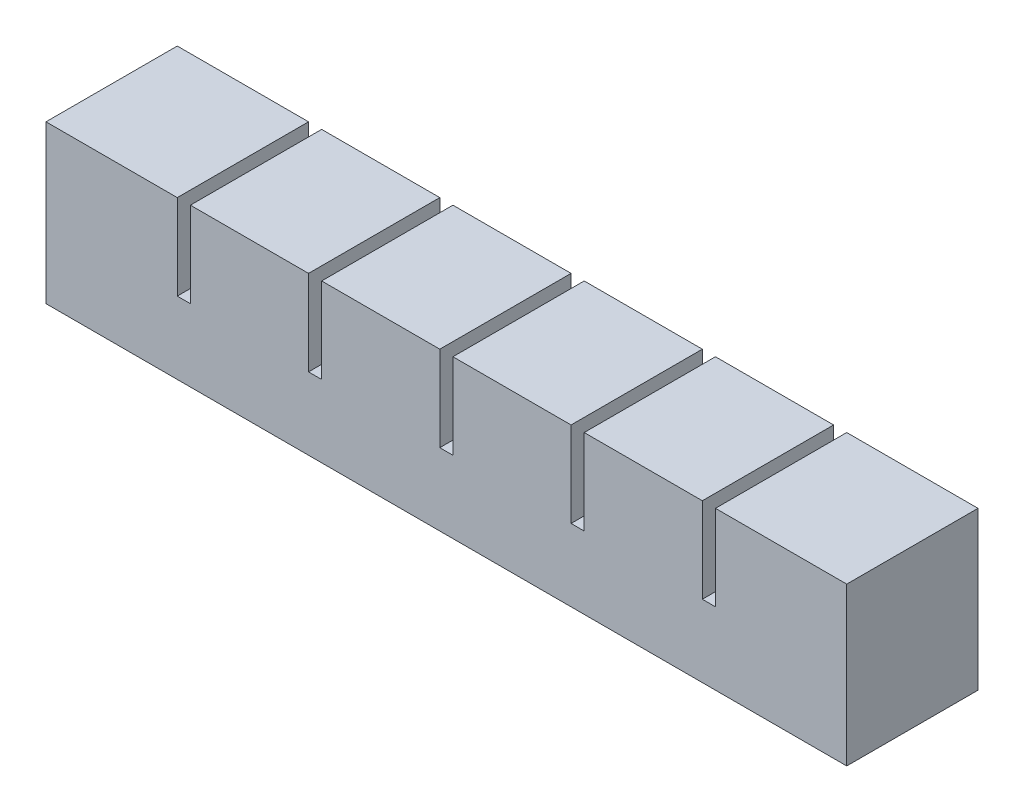
from build123d import *

# Parameters (mm, degrees)
SKETCH1_W           = 18
SKETCH1_H           = 18
BOSS_EXTRUDE1_DEPTH = 20
SKETCH2_W           = 8
SKETCH2_H           = 10
CUT_EXTRUDE1_DEPTH  = 13
SKETCH3_W           = 20
SKETCH3_H           = 5
BOSS_EXTRUDE2_DEPTH = 2
LPATTERN1_COUNT     = 6
LPATTERN1_PITCH     = 20
SKETCH4_W           = 20
SKETCH4_H           = 13
BOSS_EXTRUDE3_DEPTH = 2
SKETCH5_W           = 20
SKETCH5_H           = 18
BOSS_EXTRUDE4_DEPTH = 2
SKETCH6_W           = 108
SKETCH6_H           = 2
CUT_EXTRUDE2_DEPTH  = 2
SKETCH7_W           = 122
SKETCH7_H           = 20
BOSS_EXTRUDE5_DEPTH = 6


with BuildPart() as part:
    # Sketch1 → Boss-Extrude1 (new body)
    with BuildSketch(Plane.XY):
        with Locations((9, 9)):
            Rectangle(SKETCH1_W, SKETCH1_H)
    extrude(amount=BOSS_EXTRUDE1_DEPTH)

    # Sketch2 → Cut-Extrude1 (cut)
    with BuildSketch(Plane.XZ):
        with Locations((9, 10)):
            Rectangle(SKETCH2_W, SKETCH2_H)
    extrude(amount=-CUT_EXTRUDE1_DEPTH, mode=Mode.SUBTRACT)

    # Sketch3 → Boss-Extrude2 (add)
    with BuildSketch(Plane(origin=(18, 0, 0), x_dir=(0, 0, -1), z_dir=(1, 0, 0))):
        with Locations((-10, 2.5)):
            Rectangle(SKETCH3_W, SKETCH3_H)
    extrude(amount=BOSS_EXTRUDE2_DEPTH)


with BuildPart() as lpattern1_1:
    # LPattern1: pattern copy
    add(part.part.moved(Location(Vector(1, 0, 0) * (1 * LPATTERN1_PITCH))))


with BuildPart() as lpattern1_2:
    # LPattern1: pattern copy
    add(part.part.moved(Location(Vector(1, 0, 0) * (2 * LPATTERN1_PITCH))))


with BuildPart() as lpattern1_3:
    # LPattern1: pattern copy
    add(part.part.moved(Location(Vector(1, 0, 0) * (3 * LPATTERN1_PITCH))))


with BuildPart() as lpattern1_4:
    # LPattern1: pattern copy
    add(part.part.moved(Location(Vector(1, 0, 0) * (4 * LPATTERN1_PITCH))))


with BuildPart() as lpattern1_5:
    # LPattern1: pattern copy
    add(part.part.moved(Location(Vector(1, 0, 0) * (5 * LPATTERN1_PITCH))))


with BuildPart() as lpattern1_4_1:
    add(lpattern1_4.part)

    # Combine1: union LPattern1_5, part, LPattern1_1, LPattern1_2, LPattern1_3
    add(lpattern1_5.part)
    add(part.part)
    add(lpattern1_1.part)
    add(lpattern1_2.part)
    add(lpattern1_3.part)

    # Sketch4 → Boss-Extrude3 (add)
    with BuildSketch(Plane(origin=(118, 0, 0), x_dir=(0, 0, -1), z_dir=(1, 0, 0))):
        with Locations((-10, 11.5)):
            Rectangle(SKETCH4_W, SKETCH4_H)
    extrude(amount=BOSS_EXTRUDE3_DEPTH)

    # Sketch5 → Boss-Extrude4 (add)
    with BuildSketch(Plane.ZY):
        with Locations((10, 9)):
            Rectangle(SKETCH5_W, SKETCH5_H)
    extrude(amount=BOSS_EXTRUDE4_DEPTH)

    # Sketch6 → Cut-Extrude2 (cut)
    with BuildSketch(Plane(origin=(0, 0, 0), x_dir=(-1, 0, 0), z_dir=(0, -1, 0))):
        with Locations((-59, -10)):
            Rectangle(SKETCH6_W, SKETCH6_H)
    extrude(amount=-CUT_EXTRUDE2_DEPTH, mode=Mode.SUBTRACT)

    # Sketch7 → Boss-Extrude5 (add)
    with BuildSketch(Plane.XZ):
        with Locations((59, 10)):
            Rectangle(SKETCH7_W, SKETCH7_H)
    extrude(amount=BOSS_EXTRUDE5_DEPTH)


solid = lpattern1_4_1.part
